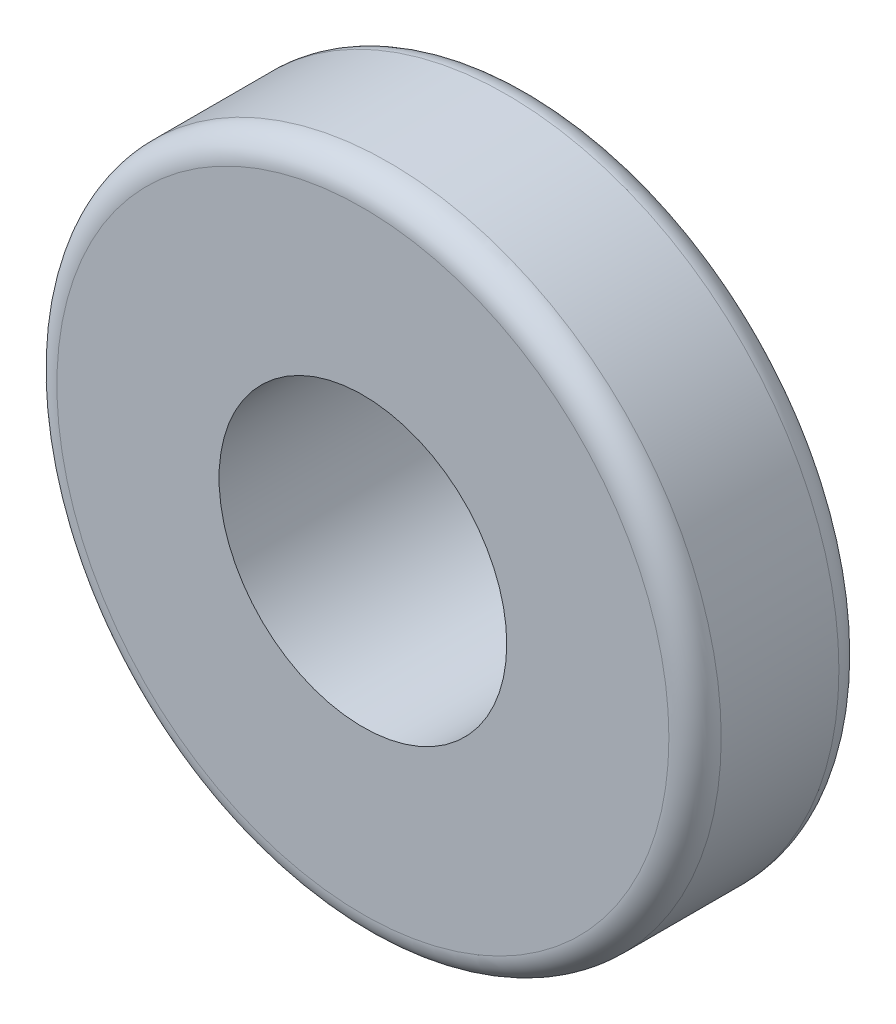
from build123d import *

# Parameters (mm, degrees)
SKETCH1_R                 = 127
TIRE_DEPTH                = 65
FILLET1_R                 = 10
SKETCH5_R                 = 67.5
TIRE_RIM_EXTRUSION_DEPTH  = 35
FILLET4_R                 = 10
SKETCH6_R                 = 55
TIRE_HOLLOW_CUT_DEPTH     = 85
SKETCH7_R                 = 22.5
SKETCH7_R_2               = 17.5
TIRE_SPLINE_HOUSING_DEPTH = 14.5


with BuildPart() as part:
    # Sketch1 → Tire (new body)
    with BuildSketch(Plane.XY):
        Circle(SKETCH1_R)
    extrude(amount=TIRE_DEPTH)

    # Fillet1
    fillet1_edges = [part.edges().sort_by_distance(p)[0] for p in [
        (-127, 0, 0),
        (-127, 0, 65),
    ]]
    fillet(fillet1_edges, radius=FILLET1_R)

    # Sketch5 → Tire_Rim_Extrusion (add)
    with BuildSketch(Plane(origin=(0, 0, 0), x_dir=(-1, 0, 0), z_dir=(0, 0, -1))):
        Circle(SKETCH5_R)
    extrude(amount=TIRE_RIM_EXTRUSION_DEPTH)

    # Fillet4
    fillet4_edges = [part.edges().sort_by_distance(p)[0] for p in [
        (67.5, 0, -35),
    ]]
    fillet(fillet4_edges, radius=FILLET4_R)

    # Sketch6 → Tire_Hollow_Cut (cut)
    with BuildSketch(Plane.XY.offset(65)):
        Circle(SKETCH6_R)
    extrude(amount=-TIRE_HOLLOW_CUT_DEPTH, mode=Mode.SUBTRACT)


with BuildPart() as body_2:
    # Sketch7 → Tire_Spline_Housing (new body)
    with BuildSketch(Plane.XY.offset(-20)):
        Circle(SKETCH7_R)
        Circle(SKETCH7_R_2, mode=Mode.SUBTRACT)
    extrude(amount=TIRE_SPLINE_HOUSING_DEPTH)


solid = Compound([part.part, body_2.part])
